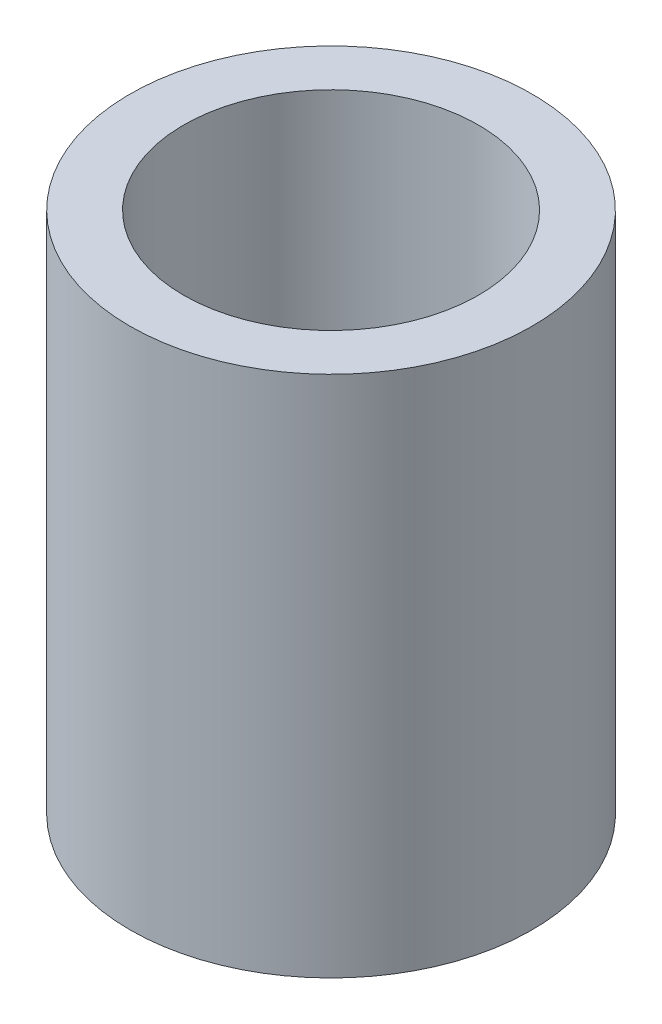
from build123d import *

# Parameters (mm, degrees)
CROQUIS1_R              = 7.5
CROQUIS1_R_2            = 5.5
SALIENTE_EXTRUIR1_DEPTH = 19.5


with BuildPart() as part:
    # Croquis1 → Saliente-Extruir1 (new body)
    with BuildSketch(Plane(origin=(0, 0, 0), x_dir=(1, 0, 0), z_dir=(0, 1, 0))):
        Circle(CROQUIS1_R)
        Circle(CROQUIS1_R_2, mode=Mode.SUBTRACT)
    extrude(amount=SALIENTE_EXTRUIR1_DEPTH)


solid = part.part
